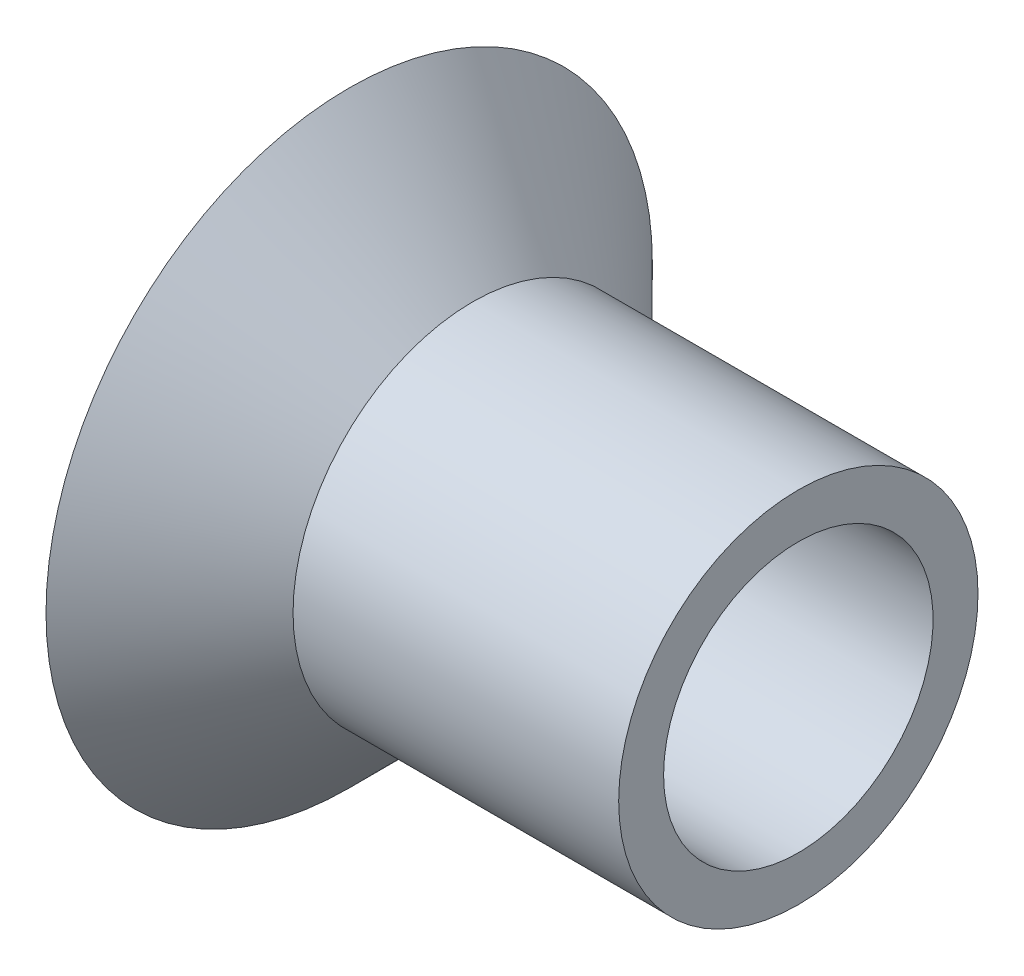
from build123d import *


with BuildPart() as part:
    # Sketch1 → Revolve1 (revolve)
    with BuildSketch(Plane.XY):
        Polygon((5, 4), (-2.25, 4), (-5, 6.75), (-5, 5.335786438), (-2.664213562, 3), (5, 3), align=None)
    revolve(axis=Axis((-9.579622459, 0, 0), (1, 0, 0)))


solid = part.part
